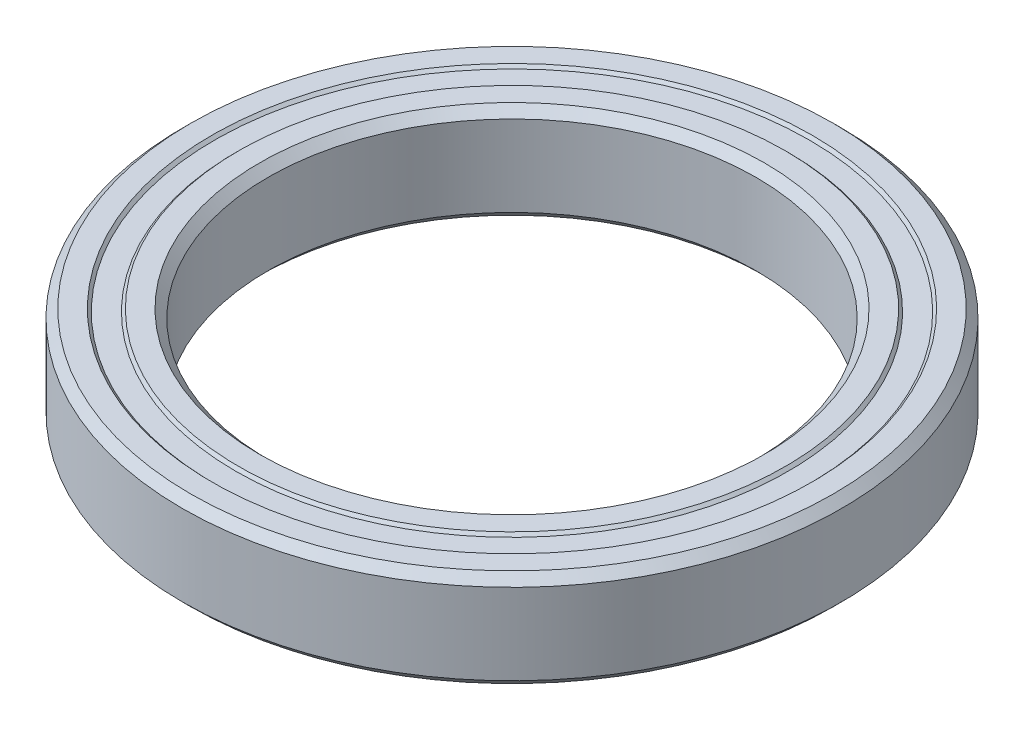
from build123d import *


with BuildPart() as part:
    # Sketch1 → Revolve1 (revolve)
    with BuildSketch(Plane.XY):
        Polygon((10, 1.65716), (10, -1.65716), (10.34284, -2), (11.19994, -2), (11.31422, -1.88572), (12.18578, -1.88572), (12.30006, -2), (13.15716, -2), (13.5, -1.65716), (13.5, 1.65716), (13.15716, 2), (12.30006, 2), (12.18578, 1.88572), (11.31422, 1.88572), (11.19994, 2), (10.34284, 2), align=None)
    revolve(axis=Axis((0, -1.349421972, 0), (0, 1, 0)))


solid = part.part
